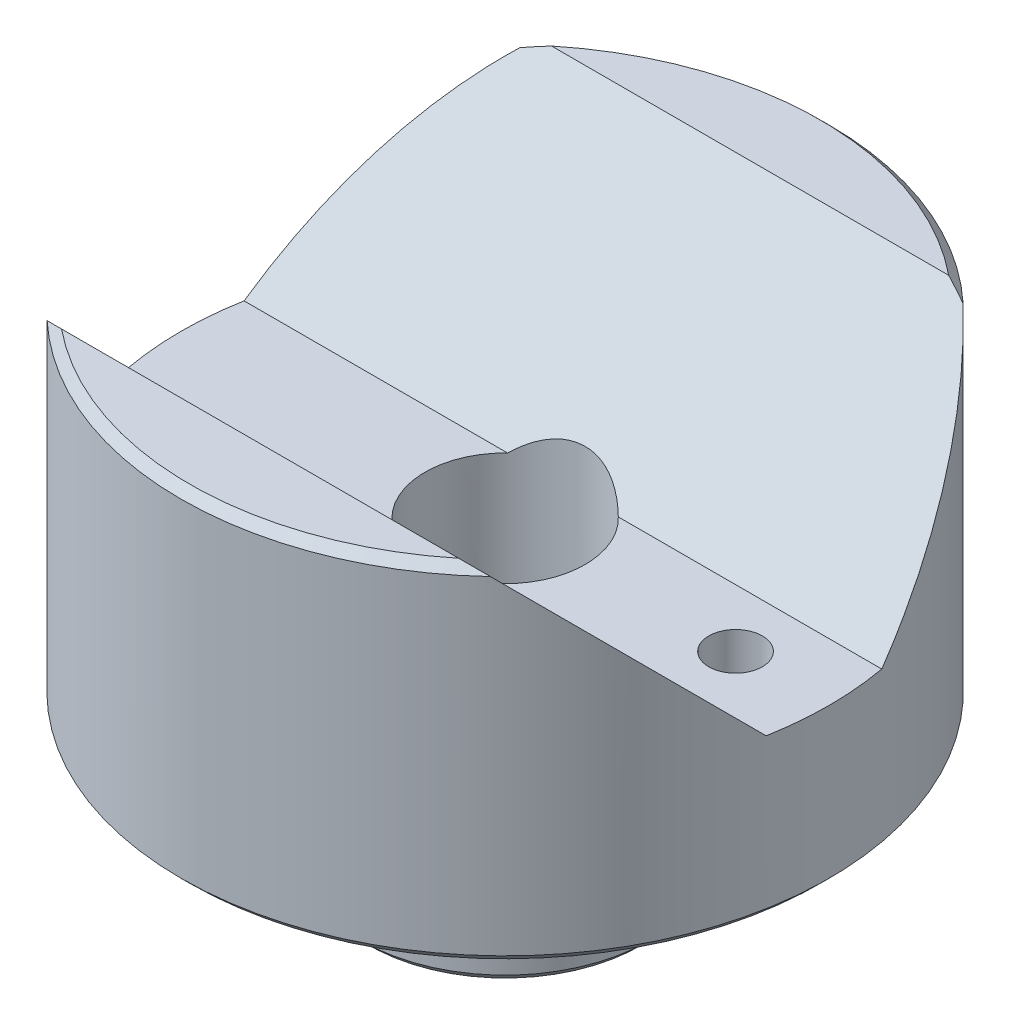
from build123d import *

# Parameters (mm, degrees)
SKETCH1_R               = 14.2875
EXTRUDE1_DEPTH          = 15.24
CUT_EXTRUDE1_DEPTH      = 15.2875
CUT_EXTRUDE1_DEPTH_BACK = 15.2875
SKETCH6_R               = 6.35
EXTRUDE2_DEPTH          = 6.35
CHAMFER1_SIZE           = 0.6223
CHAMFER2_SIZE           = 0.381
SKETCH8_R               = 0.635
SKETCH9_R               = 1.1811
CUT_EXTRUDE2_DEPTH      = 14.335


with BuildPart() as part:
    # Sketch1 → Extrude1 (new body)
    with BuildSketch(Plane(origin=(0, 0, 0), x_dir=(1, 0, 0), z_dir=(0, 1, 0))):
        with Locations(Location((0, 0, 0), (0, 0, 270))):  # turned: the seam where the file's is
            Circle(SKETCH1_R)
    extrude(amount=EXTRUDE1_DEPTH)

    # Sketch3 → Cut-Extrude1 (cut, two sides)
    with BuildSketch(Plane(origin=(0, 0, 0), x_dir=(0, 0, -1), z_dir=(1, 0, 0))) as cut_extrude1_sk:
        Polygon((-10.803384182, 15.24), (10.803384182, 15.24), (2.548384182, 6.985), (-2.548384182, 6.985), align=None)
    extrude(amount=CUT_EXTRUDE1_DEPTH, mode=Mode.SUBTRACT)
    extrude(cut_extrude1_sk.sketch, amount=-CUT_EXTRUDE1_DEPTH_BACK, mode=Mode.SUBTRACT)

    # Sketch6 → Extrude2 (add)
    with BuildSketch(Plane.XZ):
        with Locations(Location((0, 0, 0), (0, 0, 90))):  # turned: the seam where the file's is
            Circle(SKETCH6_R)
    extrude(amount=EXTRUDE2_DEPTH)

    # Sketch7 → Cut-Revolve1 (revolve, cut)
    with BuildSketch(Plane.XY, mode=Mode.PRIVATE) as cut_revolve1_sk:
        Polygon((0, -6.35), (2.5527, -6.35), (2.5527, 0.635), (3.5306, 0.635), (3.5306, 6.985), (3.5306, 15.24), (0, 15.24), (0, 6.985), align=None)
    revolve(cut_revolve1_sk.sketch.rotate(Axis((0, 13.979393491, 0), (0, -1, 0)), 90), axis=Axis((0, 13.979393491, 0), (0, -1, 0)), mode=Mode.SUBTRACT)  # turned: the seam where the file's is

    # Chamfer1
    chamfer1_edges = [part.edges().sort_by_distance(p)[0] for p in [
        (0, -6.35, -2.5527),
        (0, 0.635, -2.5527),
    ]]
    chamfer(chamfer1_edges, length=CHAMFER1_SIZE)

    # Chamfer2
    chamfer2_edges = [part.edges().sort_by_distance(p)[0] for p in [
        (0, 15.24, -14.2875),
        (-4.988953034, 15.24, 13.388166561),
        (0, 0, -14.2875),
        (0, -6.35, -6.35),
    ]]
    chamfer(chamfer2_edges, length=CHAMFER2_SIZE)

    # Sketch8 → Cut-Revolve2 (revolve, cut)
    with BuildSketch(Plane.XY, mode=Mode.PRIVATE) as cut_revolve2_sk:
        with Locations((6.6675, -0.254)):
            Circle(SKETCH8_R)
    revolve(cut_revolve2_sk.sketch.rotate(Axis((0, 0, 0), (0, -1, 0)), 90), axis=Axis((0, 0, 0), (0, -1, 0)), mode=Mode.SUBTRACT)  # turned: the seam where the file's is

    # Sketch9 → Cut-Extrude2 (cut, through all)
    with BuildSketch(Plane(origin=(0, 6.985, 0), x_dir=(-1, 0, 0), z_dir=(0, 1, 0))):
        with Locations(Location((-10.16, 0, 0), (0, 0, 90))):  # turned: the seam where the file's is
            Circle(SKETCH9_R)
    extrude(amount=-CUT_EXTRUDE2_DEPTH, mode=Mode.SUBTRACT)


solid = part.part
